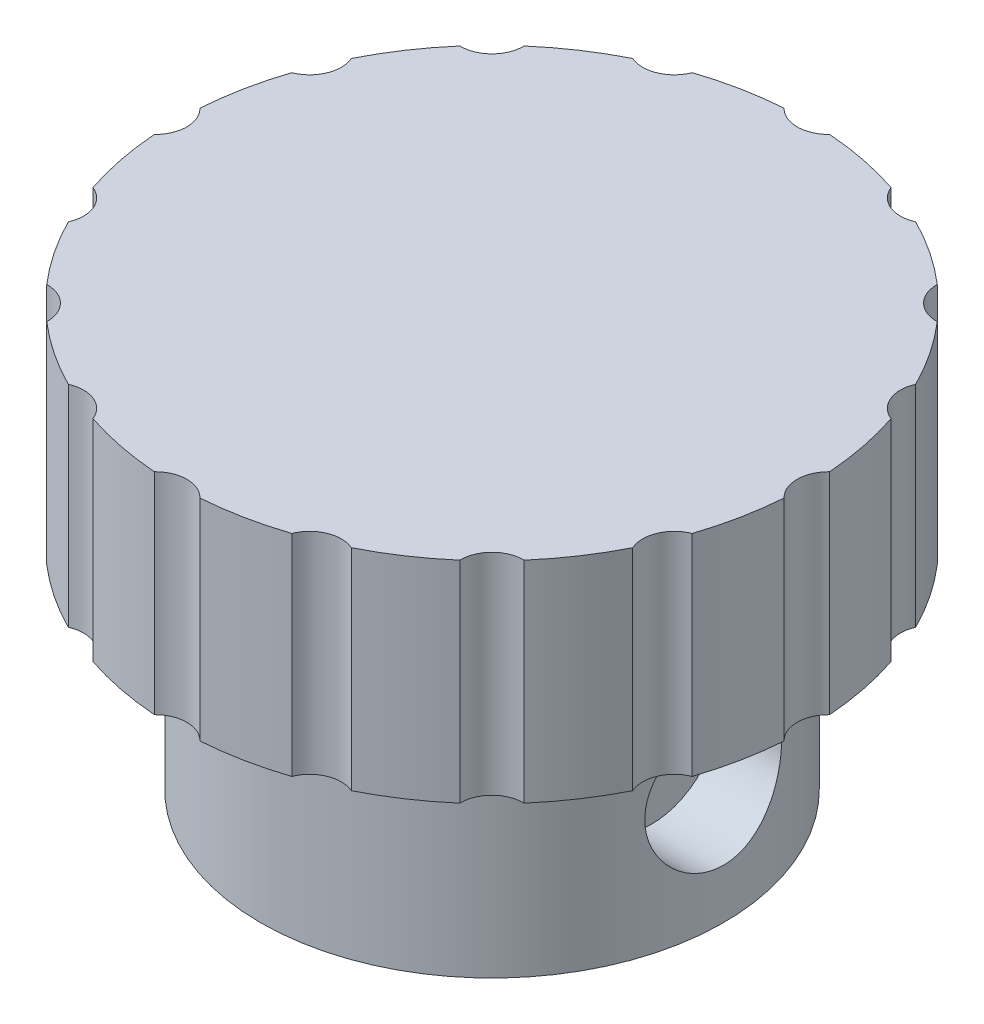
from build123d import *

# Parameters (mm, degrees)
BOSS_EXTRUDE1_DEPTH                                  = 10
SKETCH1_3_R                                          = 11
BOSS_EXTRUDE2_DEPTH                                  = 10
SCHNITT_LINEAR_AUSTRAGEN1_DEPTH                      = 10
STIRNSENKUNG_F_R_M3_ZYLINDERSCHRAUBE_MIT_D           = 2.8
STIRNSENKUNG_F_R_M3_ZYLINDERSCHRAUBE_MIT_DEPTH       = 9.1
STIRNSENKUNG_F_R_M3_ZYLINDERSCHRAUBE_MIT_CBORE_D     = 6.5
STIRNSENKUNG_F_R_M3_ZYLINDERSCHRAUBE_MIT_CBORE_DEPTH = 3.4


with BuildPart() as part:
    # Sketch1 → Boss-Extrude1 (new body)
    with BuildSketch(Plane(origin=(0, 0, 0), x_dir=(1, 0, 0), z_dir=(0, 1, 0))):
        with BuildLine():
            ThreePointArc((-1.081826752, 14.9609375), (-2.92635483, 14.711779206), (-4.72582532, 14.236101118))
            ThreePointArc((-4.72582532, 14.236101118), (-5.548909769, 13.396253221), (-6.724780508, 13.408106769))
            ThreePointArc((-6.724780508, 13.408106769), (-8.333553495, 12.472044185), (-9.814013327, 11.343947391))
            ThreePointArc((-9.814013327, 11.343947391), (-10.253048327, 10.253048327), (-11.343947391, 9.814013327))
            ThreePointArc((-11.343947391, 9.814013327), (-12.472044185, 8.333553495), (-13.408106769, 6.724780508))
            ThreePointArc((-13.408106769, 6.724780508), (-13.396253221, 5.548909769), (-14.236101118, 4.72582532))
            ThreePointArc((-14.236101118, 4.72582532), (-14.711779206, 2.92635483), (-14.9609375, 1.081826752))
            ThreePointArc((-14.9609375, 1.081826752), (-14.5, 0), (-14.9609375, -1.081826752))
            ThreePointArc((-14.9609375, -1.081826752), (-14.711779206, -2.92635483), (-14.236101118, -4.72582532))
            ThreePointArc((-14.236101118, -4.72582532), (-13.396253221, -5.548909769), (-13.408106769, -6.724780508))
            ThreePointArc((-13.408106769, -6.724780508), (-12.472044185, -8.333553495), (-11.343947391, -9.814013327))
            ThreePointArc((-11.343947391, -9.814013327), (-10.253048327, -10.253048327), (-9.814013327, -11.343947391))
            ThreePointArc((-9.814013327, -11.343947391), (-8.333553495, -12.472044185), (-6.724780508, -13.408106769))
            ThreePointArc((-6.724780508, -13.408106769), (-5.548909769, -13.396253221), (-4.72582532, -14.236101118))
            ThreePointArc((-4.72582532, -14.236101118), (-2.92635483, -14.711779206), (-1.081826752, -14.9609375))
            ThreePointArc((-1.081826752, -14.9609375), (0, -14.5), (1.081826752, -14.9609375))
            ThreePointArc((1.081826752, -14.9609375), (2.92635483, -14.711779206), (4.72582532, -14.236101118))
            ThreePointArc((4.72582532, -14.236101118), (5.548909769, -13.396253221), (6.724780508, -13.408106769))
            ThreePointArc((6.724780508, -13.408106769), (8.333553495, -12.472044185), (9.814013327, -11.343947391))
            ThreePointArc((9.814013327, -11.343947391), (10.253048327, -10.253048327), (11.343947391, -9.814013327))
            ThreePointArc((11.343947391, -9.814013327), (12.472044185, -8.333553495), (13.408106769, -6.724780508))
            ThreePointArc((13.408106769, -6.724780508), (13.396253221, -5.548909769), (14.236101118, -4.72582532))
            ThreePointArc((14.236101118, -4.72582532), (14.711779206, -2.92635483), (14.9609375, -1.081826752))
            ThreePointArc((14.9609375, -1.081826752), (14.5, 0), (14.9609375, 1.081826752))
            ThreePointArc((14.9609375, 1.081826752), (14.711779206, 2.92635483), (14.236101118, 4.72582532))
            ThreePointArc((14.236101118, 4.72582532), (13.396253221, 5.548909769), (13.408106769, 6.724780508))
            ThreePointArc((13.408106769, 6.724780508), (12.472044185, 8.333553495), (11.343947391, 9.814013327))
            ThreePointArc((11.343947391, 9.814013327), (10.253048327, 10.253048327), (9.814013327, 11.343947391))
            ThreePointArc((9.814013327, 11.343947391), (8.333553495, 12.472044185), (6.724780508, 13.408106769))
            ThreePointArc((6.724780508, 13.408106769), (5.548909769, 13.396253221), (4.72582532, 14.236101118))
            ThreePointArc((4.72582532, 14.236101118), (2.92635483, 14.711779206), (1.081826752, 14.9609375))
            ThreePointArc((1.081826752, 14.9609375), (0, 14.5), (-1.081826752, 14.9609375))
        make_face()
    extrude(amount=BOSS_EXTRUDE1_DEPTH)

    # Sketch1_3 → Boss-Extrude2 (add)
    with BuildSketch(Plane(origin=(0, 0, 0), x_dir=(1, 0, 0), z_dir=(0, 1, 0))):
        Circle(SKETCH1_3_R)
    extrude(amount=-BOSS_EXTRUDE2_DEPTH)

    # Skizze1 → Schnitt-Linear austragen1 (cut)
    with BuildSketch(Plane.XZ.offset(10)):
        with BuildLine():
            Line((1.9, 2.449489743), (1.9, -2.449489743))
            ThreePointArc((1.9, -2.449489743), (-3.1, 0), (1.9, 2.449489743))
        make_face()
    extrude(amount=-SCHNITT_LINEAR_AUSTRAGEN1_DEPTH, mode=Mode.SUBTRACT)

    # Stirnsenkung für M3 Zylinderschraube mit Innensechskant1
    with Locations(Plane.YZ.offset(11)):
        with Locations((-4.386879559, 0)):
            CounterBoreHole(STIRNSENKUNG_F_R_M3_ZYLINDERSCHRAUBE_MIT_D / 2, STIRNSENKUNG_F_R_M3_ZYLINDERSCHRAUBE_MIT_CBORE_D / 2, STIRNSENKUNG_F_R_M3_ZYLINDERSCHRAUBE_MIT_CBORE_DEPTH, depth=STIRNSENKUNG_F_R_M3_ZYLINDERSCHRAUBE_MIT_DEPTH)


solid = part.part
